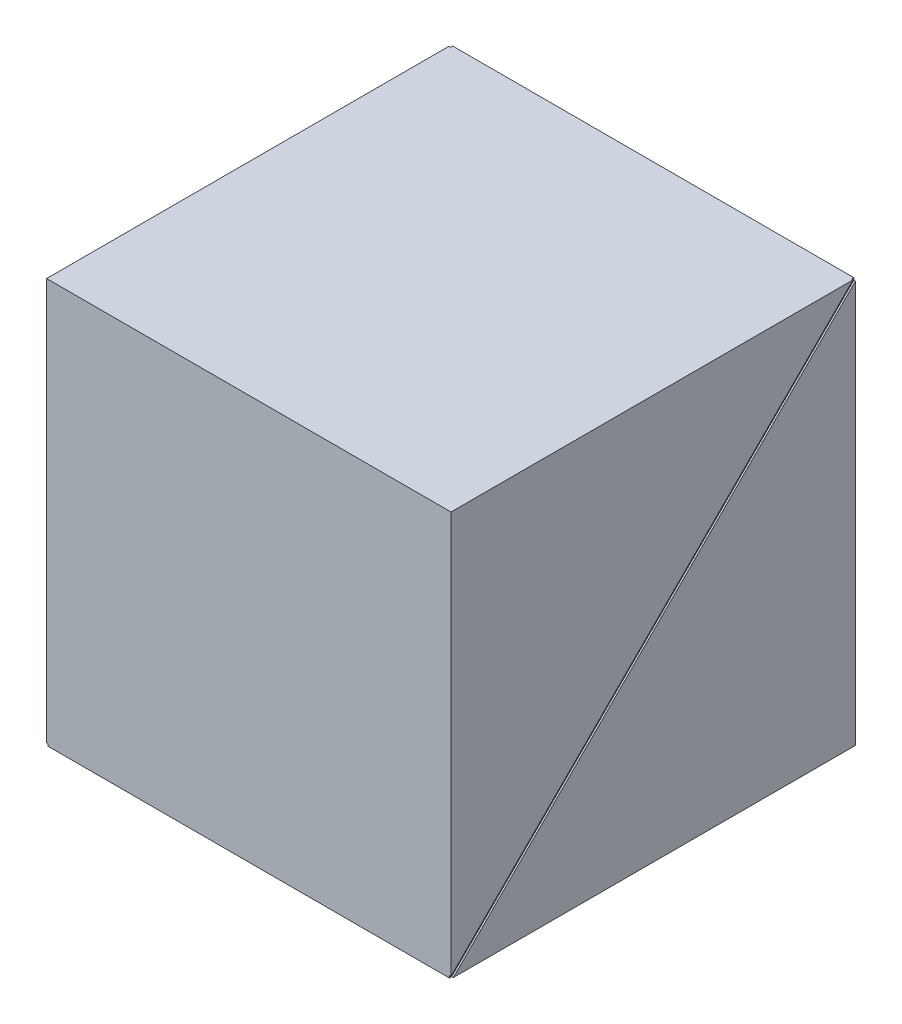
from build123d import *

# Parameters (mm, degrees)
SKETCH_1_W          = 25
SKETCH_1_H          = 25
EXTRUDE_1_DEPTH     = 25
CUT_EXTRUDE_1_DEPTH = 0.1
CUT_EXTRUDE_2_DEPTH = 0.1


with BuildPart() as part:
    # 草图1 → 凸台-拉伸1 (new body)
    with BuildSketch(Plane(origin=(0, 0, 0), x_dir=(1, 0, 0), z_dir=(0, 1, 0))):
        Rectangle(SKETCH_1_W, SKETCH_1_H)
    extrude(amount=EXTRUDE_1_DEPTH)

    # 草图2 → 切除-拉伸1 (cut)
    with BuildSketch(Plane(origin=(12.5, 0, 0), x_dir=(0, 0, -1), z_dir=(1, 0, 0))):
        Polygon((12.429289322, 25.070710678), (-12.570710678, 0.070710678), (-12.429289322, -0.070710678), (12.570710678, 24.929289322), align=None)
    extrude(amount=-CUT_EXTRUDE_1_DEPTH, mode=Mode.SUBTRACT)

    # 草图3 → 切除-拉伸2 (cut)
    with BuildSketch(Plane.ZY.offset(12.5)):
        Polygon((12.570710678, 0.070710678), (-12.429289322, 25.070710678), (-12.570710678, 24.929289322), (12.429289322, -0.070710678), align=None)
    extrude(amount=-CUT_EXTRUDE_2_DEPTH, mode=Mode.SUBTRACT)


solid = part.part
